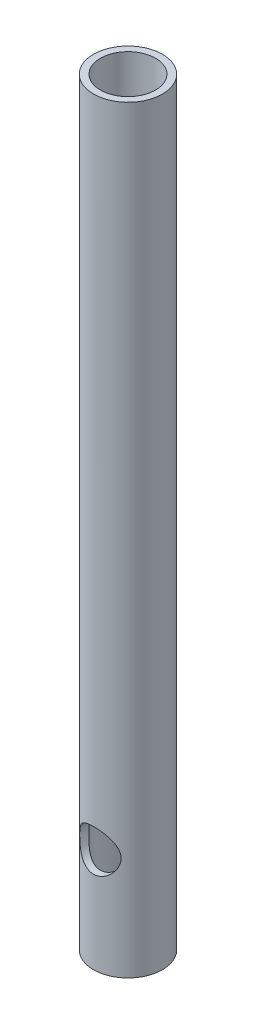
from build123d import *

# Parameters (mm, degrees)
SKETCH1_R                = 5
SKETCH1_R_2              = 4
BOSS_EXTRUDE1_DEPTH      = 80
BOSS_EXTRUDE1_DEPTH_BACK = 30
SKETCH2_R                = 3
CUT_EXTRUDE1_DEPTH       = 6
CUT_EXTRUDE1_DEPTH_BACK  = 6


with BuildPart() as part:
    # Sketch1 → Boss-Extrude1 (new body, two sides)
    with BuildSketch(Plane(origin=(0, 126.450796526, 0), x_dir=(1, 0, 0), z_dir=(0, 1, 0))) as boss_extrude1_sk:
        with Locations((87.72987116, -127.807872395)):
            Circle(SKETCH1_R)
        with Locations((87.72987116, -127.807872395)):
            Circle(SKETCH1_R_2, mode=Mode.SUBTRACT)
    extrude(amount=BOSS_EXTRUDE1_DEPTH)
    extrude(boss_extrude1_sk.sketch, amount=-BOSS_EXTRUDE1_DEPTH_BACK)

    # Sketch2 → Cut-Extrude1 (cut, two sides)
    with BuildSketch(Plane(origin=(-5.567034038, 0.110667347, 127.807872395), x_dir=(-1, 0, 0), z_dir=(0, 0, -1))) as cut_extrude1_sk:
        with Locations((-93.296905198, 111.340129179)):
            Circle(SKETCH2_R)
    extrude(amount=CUT_EXTRUDE1_DEPTH, mode=Mode.SUBTRACT)
    extrude(cut_extrude1_sk.sketch, amount=-CUT_EXTRUDE1_DEPTH_BACK, mode=Mode.SUBTRACT)


solid = part.part
